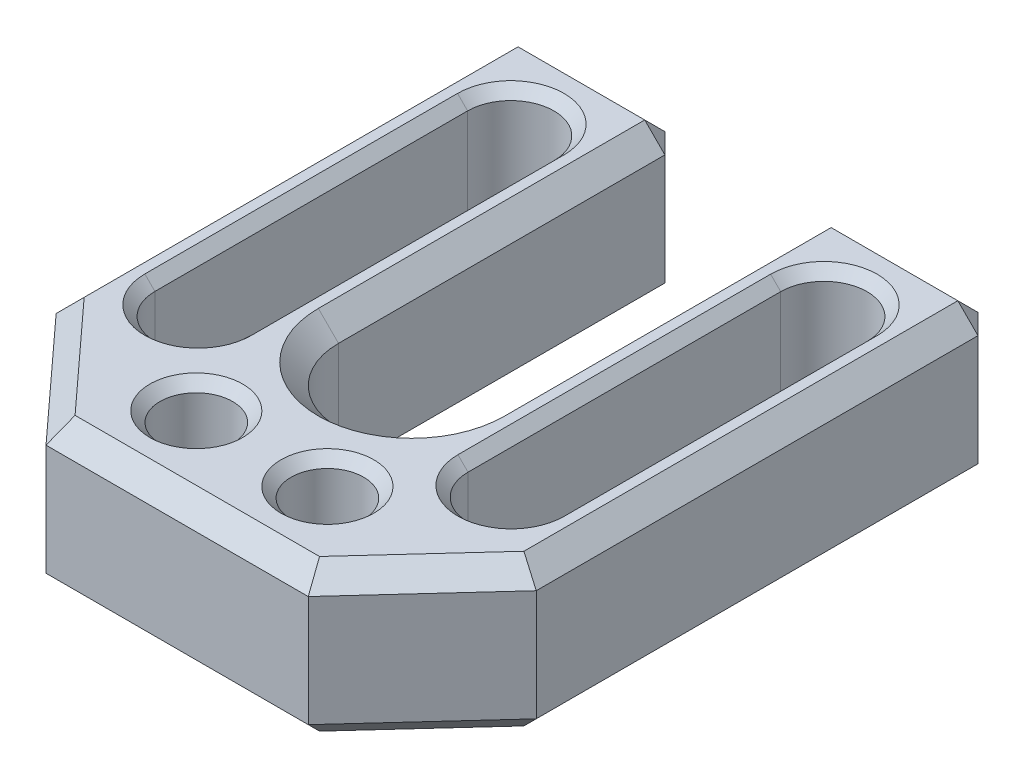
from build123d import *

# Parameters (mm, degrees)
SKETCH1_R           = 1.8
BOSS_EXTRUDE1_DEPTH = 2.5
BOSS_EXTRUDE2_START = 2.5
SKETCH1_4_R         = 1.8
BOSS_EXTRUDE2_DEPTH = 5
CHAMFER1_SIZE       = 1
CHAMFER2_SIZE       = 0.5


with BuildPart() as part:
    # Sketch1 → Boss-Extrude1 (new body)
    with BuildSketch(Plane(origin=(0, 0, 0), x_dir=(1, 0, 0), z_dir=(0, 1, 0))):
        with BuildLine():
            Line((0, -11.62), (0, -3.62))
            ThreePointArc((0, -3.62), (-2.559726548, -2.559726548), (-3.62, 0))
            Line((-3.62, 0), (-3.62, 17.18))
            Line((-3.62, 17.18), (-11.9, 17.18))
            Line((-11.9, 17.18), (-11.9, -5.717458175))
            Line((-11.9, -5.717458175), (-6.5, -11.62))
            Line((-6.5, -11.62), (0, -11.62))
        make_face()
        with Locations((-3.25, -7.42)):
            Circle(SKETCH1_R, mode=Mode.SUBTRACT)
        with BuildLine():
            ThreePointArc((-9.9, -2.82), (-7.76, -4.96), (-5.62, -2.82))
            Line((-5.62, -2.82), (-5.62, 12.68))
            ThreePointArc((-5.62, 12.68), (-7.76, 14.82), (-9.9, 12.68))
            Line((-9.9, 12.68), (-9.9, -2.82))
        make_face(mode=Mode.SUBTRACT)
        with Locations((-3.25, -7.42)):
            Circle(SKETCH1_R)
    extrude(amount=BOSS_EXTRUDE1_DEPTH)

    # Sketch1_4 → Boss-Extrude2 (add)
    with BuildSketch(Plane(origin=(0, 0, 0), x_dir=(1, 0, 0), z_dir=(0, 1, 0)).offset(BOSS_EXTRUDE2_START)):
        with BuildLine():
            Line((-3.62, 0), (-3.62, 17.18))
            Line((-3.62, 17.18), (-11.9, 17.18))
            Line((-11.9, 17.18), (-11.9, -5.717458175))
            Line((-11.9, -5.717458175), (-6.5, -11.62))
            Line((-6.5, -11.62), (0, -11.62))
            Line((0, -11.62), (0, -3.62))
            ThreePointArc((0, -3.62), (-2.559726548, -2.559726548), (-3.62, 0))
        make_face()
        with Locations(Location((-3.25, -7.42, 0), (0, 0, 270))):
            Circle(SKETCH1_4_R, mode=Mode.SUBTRACT)
        with BuildLine():
            Line((-5.62, 12.68), (-5.62, -2.82))
            ThreePointArc((-5.62, -2.82), (-7.76, -4.96), (-9.9, -2.82))
            Line((-9.9, -2.82), (-9.9, 12.68))
            ThreePointArc((-9.9, 12.68), (-7.76, 14.82), (-5.62, 12.68))
        make_face(mode=Mode.SUBTRACT)
    extrude(amount=BOSS_EXTRUDE2_DEPTH)

    # Chamfer1
    chamfer1_edges = [part.edges().sort_by_distance(p)[0] for p in [
        (-3.25, 0, 11.62),
        (-9.2, 0, 8.668729087),
        (-11.9, 0, -5.731270913),
        (-7.76, 0, -17.18),
        (-3.62, 0, -8.59),
        (-2.559726548, 0, 2.559726548),
        (-11.9, 3.75, -17.18),
        (-3.62, 3.75, -17.18),
        (-2.559726548, 7.5, 2.559726548),
        (-3.62, 7.5, -8.59),
        (-7.76, 7.5, -17.18),
        (-11.9, 7.5, -5.731270913),
        (-9.2, 7.5, 8.668729087),
        (-3.25, 7.5, 11.62),
    ]]
    chamfer(chamfer1_edges, length=CHAMFER1_SIZE)

    # Chamfer2
    chamfer2_edges = [part.edges().sort_by_distance(p)[0] for p in [
        (-5.62, 0, -4.93),
        (-7.76, 0, -14.82),
        (-9.9, 0, -4.93),
        (-7.76, 0, 4.96),
        (-5.62, 7.5, -4.93),
        (-9.9, 7.5, -4.93),
        (-7.76, 7.5, 4.96),
        (-7.76, 7.5, -14.82),
        (-3.25, 7.5, 5.62),
    ]]
    chamfer(chamfer2_edges, length=CHAMFER2_SIZE)

    # Mirror1: part across plane


with BuildPart() as part_1:
    add(part.part)
    add(part.part.mirror(Plane(origin=(0, 2.5, 0), x_dir=(0, 0, 1), z_dir=(-1, 0, 0))))


solid = part_1.part
